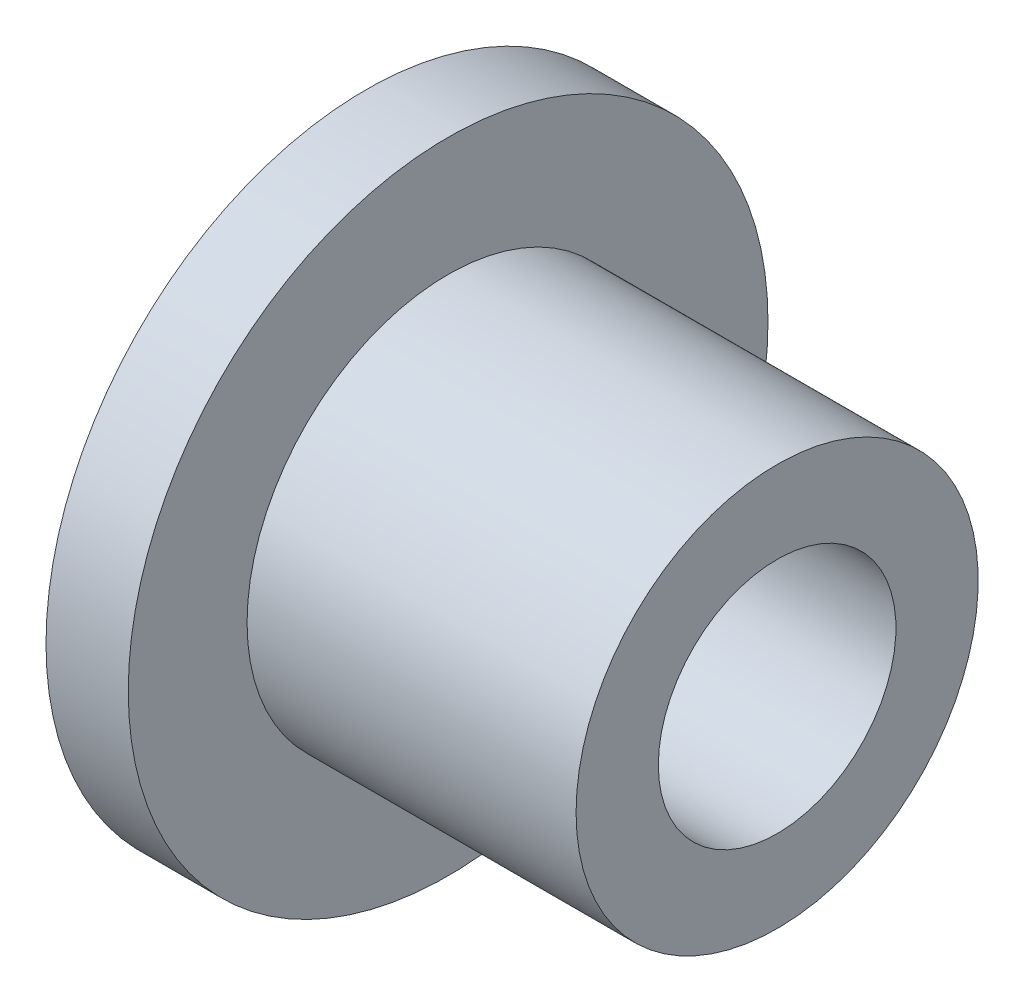
from build123d import *


with BuildPart() as part:
    # Sketch1 → Revolve1 (revolve)
    with BuildSketch(Plane.XY):
        Polygon((-1.809278351, 52.5), (-1.809278351, 15), (11.690721649, 15), (11.690721649, 19.5), (65.690721649, 19.5), (65.690721649, 33), (11.690721649, 33), (11.690721649, 52.5), align=None)
    revolve(axis=Axis((0, 0, 0), (1, 0, 0)))


solid = part.part
